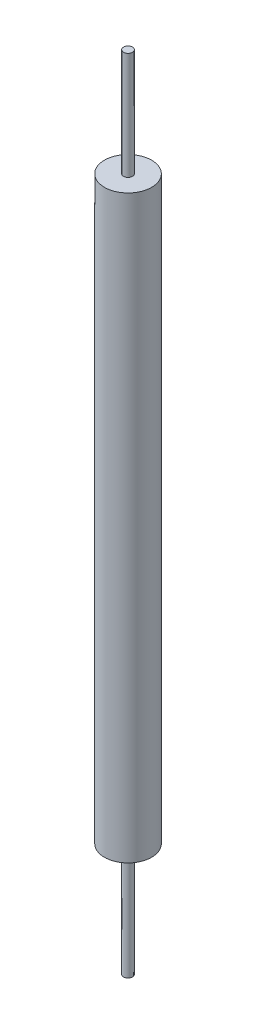
from build123d import *

# Parameters (mm, degrees)
SKETCH1_R           = 25
BOSS_EXTRUDE1_DEPTH = 789.6
SKETCH2_R           = 25
SKETCH2_R_2         = 4.7625
CUT_EXTRUDE1_DEPTH  = 74
SKETCH3_R           = 25
SKETCH3_R_2         = 4.7625
CUT_EXTRUDE2_DEPTH  = 100
SKETCH4_R           = 1.5
CUT_EXTRUDE3_DEPTH  = 30
SKETCH5_R           = 4.7625
BOSS_EXTRUDE3_DEPTH = 20
SKETCH6_R           = 4.7625
BOSS_EXTRUDE4_DEPTH = 40


with BuildPart() as part:
    # Sketch1 → Boss-Extrude1 (new body)
    with BuildSketch(Plane(origin=(0, 0, 0), x_dir=(1, 0, 0), z_dir=(0, 1, 0))):
        Circle(SKETCH1_R)
    extrude(amount=BOSS_EXTRUDE1_DEPTH)

    # Sketch2 → Cut-Extrude1 (cut)
    with BuildSketch(Plane(origin=(0, 789.6, 0), x_dir=(1, 0, 0), z_dir=(0, 1, 0))):
        Circle(SKETCH2_R)
        Circle(SKETCH2_R_2, mode=Mode.SUBTRACT)
    extrude(amount=-CUT_EXTRUDE1_DEPTH, mode=Mode.SUBTRACT)

    # Sketch3 → Cut-Extrude2 (cut)
    with BuildSketch(Plane.XZ):
        Circle(SKETCH3_R)
        Circle(SKETCH3_R_2, mode=Mode.SUBTRACT)
    extrude(amount=-CUT_EXTRUDE2_DEPTH, mode=Mode.SUBTRACT)

    # Sketch4 → Cut-Extrude3 (cut)
    with BuildSketch(Plane(origin=(0, 0, 0), x_dir=(0, 0, -1), z_dir=(1, 0, 0))):
        with Locations((3.570652979, 337.95)):
            Circle(SKETCH4_R)
    extrude(amount=-CUT_EXTRUDE3_DEPTH, mode=Mode.SUBTRACT)

    # Sketch5 → Boss-Extrude3 (add)
    with BuildSketch(Plane.XZ):
        Circle(SKETCH5_R)
    extrude(amount=BOSS_EXTRUDE3_DEPTH)

    # Sketch6 → Boss-Extrude4 (add)
    with BuildSketch(Plane(origin=(0, 789.6, 0), x_dir=(1, 0, 0), z_dir=(0, 1, 0))):
        Circle(SKETCH6_R)
    extrude(amount=BOSS_EXTRUDE4_DEPTH)


solid = part.part
